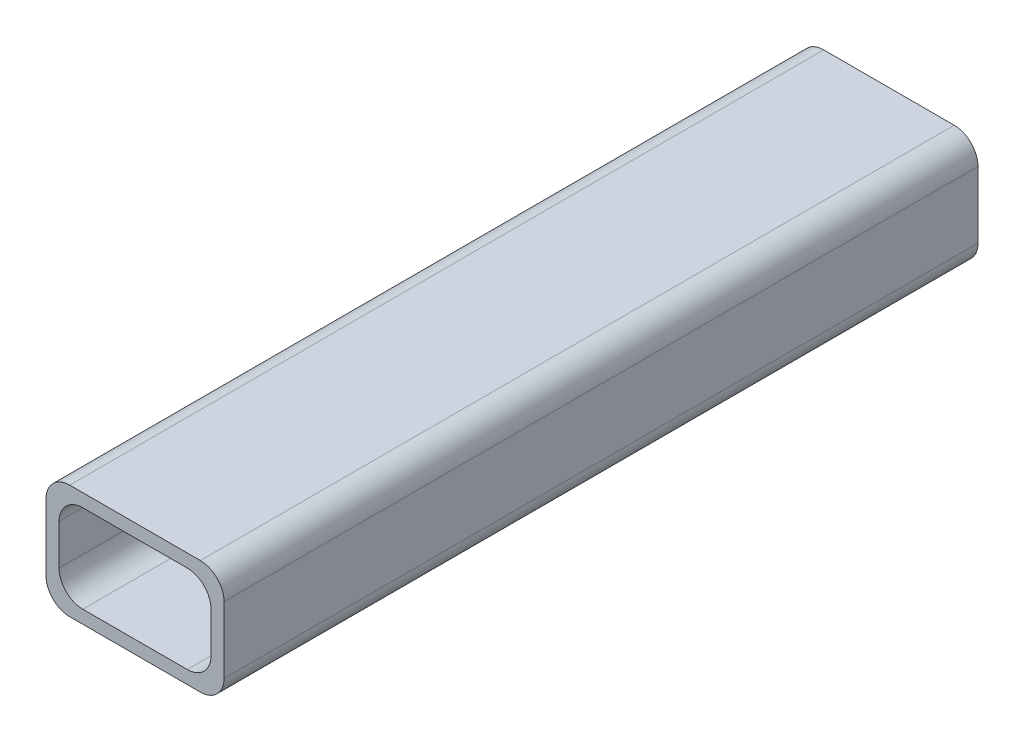
from build123d import *

# Parameters (mm, degrees)
ESQUISSE1_W             = 30
ESQUISSE1_H             = 19.2
ESQUISSE1_W_2           = 25.6
ESQUISSE1_H_2           = 14.8
BOSS_EXTRU_1_DEPTH      = 63.5
BOSS_EXTRU_1_DEPTH_BACK = 63.5
CONG_3_R                = 4


with BuildPart() as part:
    # Esquisse1 → Boss.-Extru.1 (new body, two sides)
    with BuildSketch(Plane.XY) as boss_extru_1_sk:
        Rectangle(ESQUISSE1_W, ESQUISSE1_H)
        Rectangle(ESQUISSE1_W_2, ESQUISSE1_H_2, mode=Mode.SUBTRACT)
    extrude(amount=BOSS_EXTRU_1_DEPTH)
    extrude(boss_extru_1_sk.sketch, amount=-BOSS_EXTRU_1_DEPTH_BACK)

    # Cong_3
    cong_3_edges = [part.edges().sort_by_distance(p)[0] for p in [
        (12.8, 7.4, 0),
        (12.8, -7.4, 0),
        (-12.8, -7.4, 0),
        (-12.8, 7.4, 0),
        (15, -9.6, 0),
        (-15, -9.6, 0),
        (-15, 9.6, 0),
        (15, 9.6, 0),
    ]]
    fillet(cong_3_edges, radius=CONG_3_R)


solid = part.part
